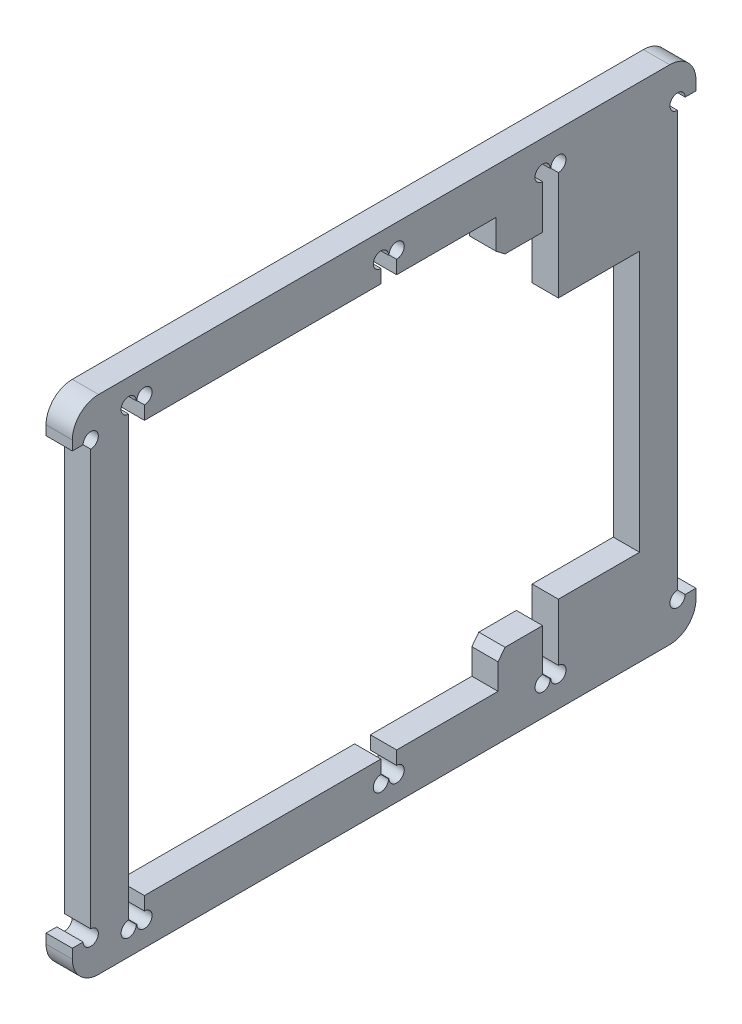
from build123d import *

# Parameters (mm, degrees)
BOSS_EXTRUDE1_DEPTH = 5
FILLET1_R           = 5
CUT_EXTRUDE1_REACH  = 7
SKETCH2_W           = 3
SKETCH2_H           = 4
CUT_EXTRUDE2_REACH  = 7
SKETCH3_R           = 1.45


with BuildPart() as part:
    # Sketch1 → Boss-Extrude1 (new body)
    with BuildSketch(Plane(origin=(0, 0, 0), x_dir=(0, 0, -1), z_dir=(1, 0, 0))):
        Polygon((-59.36916415, -47.818646587), (0, -47.818646587), (59.36916415, -47.818646587), (59.36916415, -41), (55.86916415, -41), (55.86916415, 41), (59.36916415, 41), (59.36916415, 47.818646587), (-59.36916415, 47.818646587), (-59.36916415, 41), (-55.86916415, 41), (-55.86916415, -41), (-59.36916415, -41), align=None)
        Polygon((21.702610628, -39.175443067), (21.702610628, -34.307045578), (23.024909313, -32.569779859), (30.179141539, -32.569779859), (30.179141539, -42.076978078), (33.179141539, -42.076978078), (33.179141539, -29.710380013), (48.63820865, -29.710380013), (48.63820865, 19.945173818), (33.179141539, 19.945173818), (33.179141539, 42.076978078), (30.179141539, 42.076978078), (30.179141539, 32.288188968), (23.024909313, 32.288188968), (21.287643594, 33.610487654), (21.287643594, 39.175443067), (-48.63820865, 39.175443067), (-48.63820865, -39.175443067), align=None, mode=Mode.SUBTRACT)
    extrude(amount=BOSS_EXTRUDE1_DEPTH)

    # Fillet1
    fillet1_edges = [part.edges().sort_by_distance(p)[0] for p in [
        (2.5, -47.818646587, -59.36916415),
        (2.5, -47.818646587, 59.36916415),
        (2.5, 47.818646587, 59.36916415),
        (2.5, 47.818646587, -59.36916415),
    ]]
    fillet(fillet1_edges, radius=FILLET1_R)

    # Sketch2 → Cut-Extrude1 (cut, up to next)
    with BuildSketch(Plane.ZY, mode=Mode.PRIVATE) as cut_extrude1_sk1:
        with Locations((47.13820865, 41.175443067)):
            Rectangle(SKETCH2_W, SKETCH2_H)
    cut_extrude1_tool1 = extrude(cut_extrude1_sk1.sketch, amount=-CUT_EXTRUDE1_REACH, mode=Mode.PRIVATE) & part.part
    add(cut_extrude1_tool1.solids().sort_by_distance((0, 41.175443, 47.138209))[0], mode=Mode.SUBTRACT)
    # Sketch2 → Cut-Extrude1 (cut, up to next)
    with BuildSketch(Plane.ZY, mode=Mode.PRIVATE) as cut_extrude1_sk2:
        with Locations((47.13820865, -41.175443067)):
            Rectangle(SKETCH2_W, SKETCH2_H)
    cut_extrude1_tool2 = extrude(cut_extrude1_sk2.sketch, amount=-CUT_EXTRUDE1_REACH, mode=Mode.PRIVATE) & part.part
    add(cut_extrude1_tool2.solids().sort_by_distance((0, -41.175443, 47.138209))[0], mode=Mode.SUBTRACT)
    # Sketch2 → Cut-Extrude1 (cut, up to next)
    with BuildSketch(Plane.ZY, mode=Mode.PRIVATE) as cut_extrude1_sk3:
        with Locations((-0.884341096, -41.175443067)):
            Rectangle(SKETCH2_W, SKETCH2_H)
    cut_extrude1_tool3 = extrude(cut_extrude1_sk3.sketch, amount=-CUT_EXTRUDE1_REACH, mode=Mode.PRIVATE) & part.part
    add(cut_extrude1_tool3.solids().sort_by_distance((0, -41.175443, -0.884341))[0], mode=Mode.SUBTRACT)
    # Sketch2 → Cut-Extrude1 (cut, up to next)
    with BuildSketch(Plane.ZY, mode=Mode.PRIVATE) as cut_extrude1_sk4:
        with Locations((-0.884341096, 41.175443067)):
            Rectangle(SKETCH2_W, SKETCH2_H)
    cut_extrude1_tool4 = extrude(cut_extrude1_sk4.sketch, amount=-CUT_EXTRUDE1_REACH, mode=Mode.PRIVATE) & part.part
    add(cut_extrude1_tool4.solids().sort_by_distance((0, 41.175443, -0.884341))[0], mode=Mode.SUBTRACT)

    # Sketch3 → Cut-Extrude2 (cut, up to next)
    with BuildSketch(Plane.ZY, mode=Mode.PRIVATE) as cut_extrude2_sk1:
        with Locations((-33.179141539, 42.076978078)):
            Circle(SKETCH3_R)
    cut_extrude2_tool1 = extrude(cut_extrude2_sk1.sketch, amount=-CUT_EXTRUDE2_REACH, mode=Mode.PRIVATE) & part.part
    add(cut_extrude2_tool1.solids().sort_by_distance((0, 42.076978, -33.179142))[0], mode=Mode.SUBTRACT)
    # Sketch3 → Cut-Extrude2 (cut, up to next)
    with BuildSketch(Plane.ZY, mode=Mode.PRIVATE) as cut_extrude2_sk2:
        with Locations((-30.179141539, 42.076978078)):
            Circle(SKETCH3_R)
    cut_extrude2_tool2 = extrude(cut_extrude2_sk2.sketch, amount=-CUT_EXTRUDE2_REACH, mode=Mode.PRIVATE) & part.part
    add(cut_extrude2_tool2.solids().sort_by_distance((0, 42.076978, -30.179142))[0], mode=Mode.SUBTRACT)
    # Sketch3 → Cut-Extrude2 (cut, up to next)
    with BuildSketch(Plane.ZY, mode=Mode.PRIVATE) as cut_extrude2_sk3:
        with Locations((-2.384341096, 43.175443067)):
            Circle(SKETCH3_R)
    cut_extrude2_tool3 = extrude(cut_extrude2_sk3.sketch, amount=-CUT_EXTRUDE2_REACH, mode=Mode.PRIVATE) & part.part
    add(cut_extrude2_tool3.solids().sort_by_distance((0, 43.175443, -2.384341))[0], mode=Mode.SUBTRACT)
    # Sketch3 → Cut-Extrude2 (cut, up to next)
    with BuildSketch(Plane.ZY, mode=Mode.PRIVATE) as cut_extrude2_sk4:
        with Locations((0.615658904, 43.175443067)):
            Circle(SKETCH3_R)
    cut_extrude2_tool4 = extrude(cut_extrude2_sk4.sketch, amount=-CUT_EXTRUDE2_REACH, mode=Mode.PRIVATE) & part.part
    add(cut_extrude2_tool4.solids().sort_by_distance((0, 43.175443, 0.615659))[0], mode=Mode.SUBTRACT)
    # Sketch3 → Cut-Extrude2 (cut, up to next)
    with BuildSketch(Plane.ZY, mode=Mode.PRIVATE) as cut_extrude2_sk5:
        with Locations((-55.86916415, 41)):
            Circle(SKETCH3_R)
    cut_extrude2_tool5 = extrude(cut_extrude2_sk5.sketch, amount=-CUT_EXTRUDE2_REACH, mode=Mode.PRIVATE) & part.part
    add(cut_extrude2_tool5.solids().sort_by_distance((0, 41, -55.869164))[0], mode=Mode.SUBTRACT)
    # Sketch3 → Cut-Extrude2 (cut, up to next)
    with BuildSketch(Plane.ZY, mode=Mode.PRIVATE) as cut_extrude2_sk6:
        with Locations((45.63820865, 43.175443067)):
            Circle(SKETCH3_R)
    cut_extrude2_tool6 = extrude(cut_extrude2_sk6.sketch, amount=-CUT_EXTRUDE2_REACH, mode=Mode.PRIVATE) & part.part
    add(cut_extrude2_tool6.solids().sort_by_distance((0, 43.175443, 45.638209))[0], mode=Mode.SUBTRACT)
    # Sketch3 → Cut-Extrude2 (cut, up to next)
    with BuildSketch(Plane.ZY, mode=Mode.PRIVATE) as cut_extrude2_sk7:
        with Locations((48.63820865, 43.175443067)):
            Circle(SKETCH3_R)
    cut_extrude2_tool7 = extrude(cut_extrude2_sk7.sketch, amount=-CUT_EXTRUDE2_REACH, mode=Mode.PRIVATE) & part.part
    add(cut_extrude2_tool7.solids().sort_by_distance((0, 43.175443, 48.638209))[0], mode=Mode.SUBTRACT)
    # Sketch3 → Cut-Extrude2 (cut, up to next)
    with BuildSketch(Plane.ZY, mode=Mode.PRIVATE) as cut_extrude2_sk8:
        with Locations((48.63820865, -43.175443067)):
            Circle(SKETCH3_R)
    cut_extrude2_tool8 = extrude(cut_extrude2_sk8.sketch, amount=-CUT_EXTRUDE2_REACH, mode=Mode.PRIVATE) & part.part
    add(cut_extrude2_tool8.solids().sort_by_distance((0, -43.175443, 48.638209))[0], mode=Mode.SUBTRACT)
    # Sketch3 → Cut-Extrude2 (cut, up to next)
    with BuildSketch(Plane.ZY, mode=Mode.PRIVATE) as cut_extrude2_sk9:
        with Locations((45.63820865, -43.175443067)):
            Circle(SKETCH3_R)
    cut_extrude2_tool9 = extrude(cut_extrude2_sk9.sketch, amount=-CUT_EXTRUDE2_REACH, mode=Mode.PRIVATE) & part.part
    add(cut_extrude2_tool9.solids().sort_by_distance((0, -43.175443, 45.638209))[0], mode=Mode.SUBTRACT)
    # Sketch3 → Cut-Extrude2 (cut, up to next)
    with BuildSketch(Plane.ZY, mode=Mode.PRIVATE) as cut_extrude2_sk10:
        with Locations((0.615658904, -43.175443067)):
            Circle(SKETCH3_R)
    cut_extrude2_tool10 = extrude(cut_extrude2_sk10.sketch, amount=-CUT_EXTRUDE2_REACH, mode=Mode.PRIVATE) & part.part
    add(cut_extrude2_tool10.solids().sort_by_distance((0, -43.175443, 0.615659))[0], mode=Mode.SUBTRACT)
    # Sketch3 → Cut-Extrude2 (cut, up to next)
    with BuildSketch(Plane.ZY, mode=Mode.PRIVATE) as cut_extrude2_sk11:
        with Locations((-2.384341096, -43.175443067)):
            Circle(SKETCH3_R)
    cut_extrude2_tool11 = extrude(cut_extrude2_sk11.sketch, amount=-CUT_EXTRUDE2_REACH, mode=Mode.PRIVATE) & part.part
    add(cut_extrude2_tool11.solids().sort_by_distance((0, -43.175443, -2.384341))[0], mode=Mode.SUBTRACT)
    # Sketch3 → Cut-Extrude2 (cut, up to next)
    with BuildSketch(Plane.ZY, mode=Mode.PRIVATE) as cut_extrude2_sk12:
        with Locations((-30.179141539, -42.076978078)):
            Circle(SKETCH3_R)
    cut_extrude2_tool12 = extrude(cut_extrude2_sk12.sketch, amount=-CUT_EXTRUDE2_REACH, mode=Mode.PRIVATE) & part.part
    add(cut_extrude2_tool12.solids().sort_by_distance((0, -42.076978, -30.179142))[0], mode=Mode.SUBTRACT)
    # Sketch3 → Cut-Extrude2 (cut, up to next)
    with BuildSketch(Plane.ZY, mode=Mode.PRIVATE) as cut_extrude2_sk13:
        with Locations((-33.179141539, -42.076978078)):
            Circle(SKETCH3_R)
    cut_extrude2_tool13 = extrude(cut_extrude2_sk13.sketch, amount=-CUT_EXTRUDE2_REACH, mode=Mode.PRIVATE) & part.part
    add(cut_extrude2_tool13.solids().sort_by_distance((0, -42.076978, -33.179142))[0], mode=Mode.SUBTRACT)
    # Sketch3 → Cut-Extrude2 (cut, up to next)
    with BuildSketch(Plane.ZY, mode=Mode.PRIVATE) as cut_extrude2_sk14:
        with Locations((-55.86916415, -41)):
            Circle(SKETCH3_R)
    cut_extrude2_tool14 = extrude(cut_extrude2_sk14.sketch, amount=-CUT_EXTRUDE2_REACH, mode=Mode.PRIVATE) & part.part
    add(cut_extrude2_tool14.solids().sort_by_distance((0, -41, -55.869164))[0], mode=Mode.SUBTRACT)
    # Sketch3 → Cut-Extrude2 (cut, up to next)
    with BuildSketch(Plane.ZY, mode=Mode.PRIVATE) as cut_extrude2_sk15:
        with Locations((55.86916415, -41)):
            Circle(SKETCH3_R)
    cut_extrude2_tool15 = extrude(cut_extrude2_sk15.sketch, amount=-CUT_EXTRUDE2_REACH, mode=Mode.PRIVATE) & part.part
    add(cut_extrude2_tool15.solids().sort_by_distance((0, -41, 55.869164))[0], mode=Mode.SUBTRACT)
    # Sketch3 → Cut-Extrude2 (cut, up to next)
    with BuildSketch(Plane.ZY, mode=Mode.PRIVATE) as cut_extrude2_sk16:
        with Locations((55.86916415, 41)):
            Circle(SKETCH3_R)
    cut_extrude2_tool16 = extrude(cut_extrude2_sk16.sketch, amount=-CUT_EXTRUDE2_REACH, mode=Mode.PRIVATE) & part.part
    add(cut_extrude2_tool16.solids().sort_by_distance((0, 41, 55.869164))[0], mode=Mode.SUBTRACT)


solid = part.part
